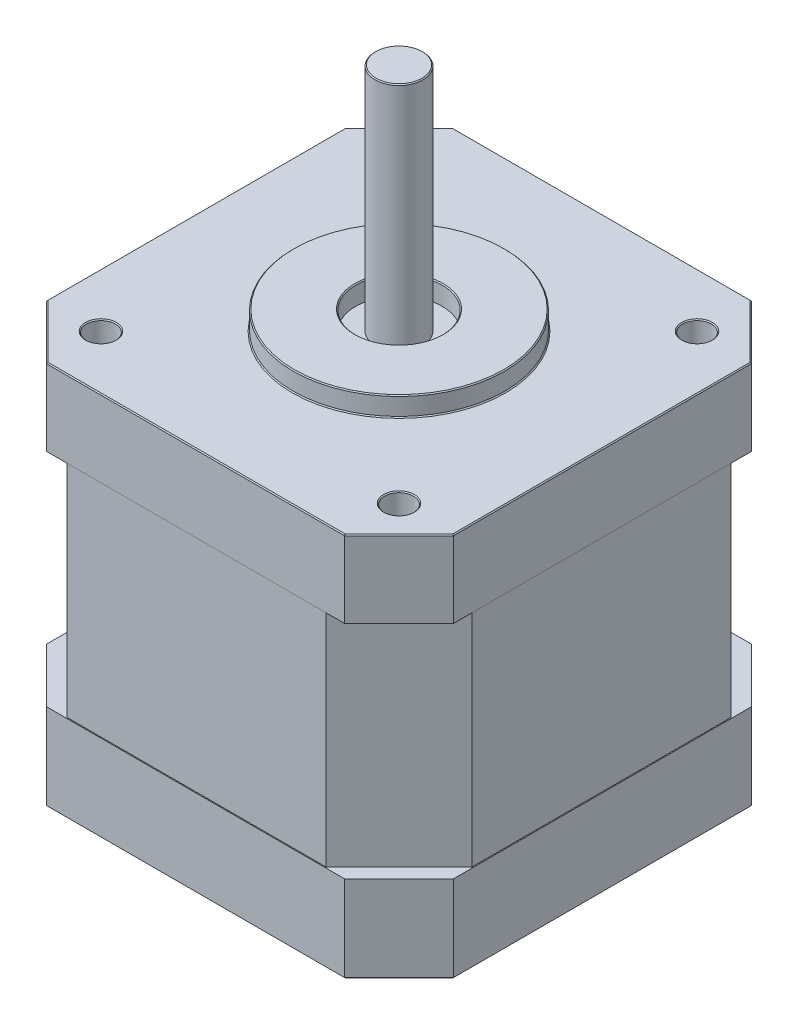
from build123d import *

# Parameters (mm, degrees)
SKETCH1_R           = 1.5
BOSS_EXTRUDE1_DEPTH = 9
SKETCH4_R           = 1.5
BOSS_EXTRUDE4_DEPTH = 23
SKETCH5_R           = 1.5
BOSS_EXTRUDE6_DEPTH = 8
SKETCH2_R           = 11
SKETCH2_R_2         = 4.5
BOSS_EXTRUDE2_DEPTH = 2
SKETCH3_R           = 2.5
BOSS_EXTRUDE3_DEPTH = 24
CHAMFER1_SIZE       = 0.1


with BuildPart() as part:
    # Sketch1 → Boss-Extrude1 (new body)
    with BuildSketch(Plane(origin=(0, 0, 0), x_dir=(1, 0, 0), z_dir=(0, 1, 0))):
        Polygon((-15.5, -21.15), (15.5, -21.15), (21.15, -15.5), (21.15, 15.5), (15.5, 21.15), (-15.5, 21.15), (-21.15, 15.5), (-21.15, -15.5), align=None)
        with Locations((-15.5, 15.5)):
            Circle(SKETCH1_R, mode=Mode.SUBTRACT)
        with Locations((15.5, -15.5)):
            Circle(SKETCH1_R, mode=Mode.SUBTRACT)
        with Locations((15.5, 15.5)):
            Circle(SKETCH1_R, mode=Mode.SUBTRACT)
        with Locations((-15.5, -15.5)):
            Circle(SKETCH1_R, mode=Mode.SUBTRACT)
    extrude(amount=BOSS_EXTRUDE1_DEPTH)

    # Sketch4 → Boss-Extrude4 (add)
    with BuildSketch(Plane(origin=(0, 9, 0), x_dir=(1, 0, 0), z_dir=(0, 1, 0))):
        Polygon((13.478679656, 21.05), (-13.478679656, 21.05), (-21.05, 13.478679656), (-21.05, -13.478679656), (-13.478679656, -21.05), (13.478679656, -21.05), (21.05, -13.478679656), (21.05, 13.478679656), align=None)
        with Locations((-15.5, 15.5)):
            Circle(SKETCH4_R, mode=Mode.SUBTRACT)
        with Locations((15.5, 15.5)):
            Circle(SKETCH4_R, mode=Mode.SUBTRACT)
        with Locations((15.5, -15.5)):
            Circle(SKETCH4_R, mode=Mode.SUBTRACT)
        with Locations((-15.5, -15.5)):
            Circle(SKETCH4_R, mode=Mode.SUBTRACT)
    extrude(amount=BOSS_EXTRUDE4_DEPTH)

    # Sketch5 → Boss-Extrude6 (add)
    with BuildSketch(Plane(origin=(0, 32, 0), x_dir=(1, 0, 0), z_dir=(0, 1, 0))):
        Polygon((-15.5, 21.15), (-21.15, 15.5), (-21.15, -15.5), (-15.5, -21.15), (15.5, -21.15), (21.15, -15.5), (21.15, 15.5), (15.5, 21.15), align=None)
        with Locations((15.5, 15.5)):
            Circle(SKETCH5_R, mode=Mode.SUBTRACT)
        with Locations((-15.5, 15.5)):
            Circle(SKETCH5_R, mode=Mode.SUBTRACT)
        with Locations((-15.5, -15.5)):
            Circle(SKETCH5_R, mode=Mode.SUBTRACT)
        with Locations((15.5, -15.5)):
            Circle(SKETCH5_R, mode=Mode.SUBTRACT)
    extrude(amount=BOSS_EXTRUDE6_DEPTH)

    # Sketch2 → Boss-Extrude2 (add)
    with BuildSketch(Plane(origin=(0, 40, 0), x_dir=(1, 0, 0), z_dir=(0, 1, 0))):
        Circle(SKETCH2_R)
        Circle(SKETCH2_R_2, mode=Mode.SUBTRACT)
    extrude(amount=BOSS_EXTRUDE2_DEPTH)

    # Sketch3 → Boss-Extrude3 (add)
    with BuildSketch(Plane(origin=(0, 40, 0), x_dir=(1, 0, 0), z_dir=(0, 1, 0))):
        Circle(SKETCH3_R)
    extrude(amount=BOSS_EXTRUDE3_DEPTH)

    # Chamfer1
    chamfer1_edges = [part.edges().sort_by_distance(p)[0] for p in [
        (-21.15, 0, 0),
        (-18.325, 0, -18.325),
        (-11, 42, 0),
        (-11, 40, 0),
        (-4.5, 42, 0),
        (-2.5, 64, 0),
        (-17, 0, -15.5),
        (14, 0, 15.5),
        (14, 0, -15.5),
        (-17, 0, 15.5),
        (0, 40, -21.15),
        (-18.325, 40, -18.325),
        (-21.15, 40, 0),
        (-18.325, 40, 18.325),
        (0, 40, 21.15),
        (18.325, 40, 18.325),
        (21.15, 40, 0),
        (18.325, 40, -18.325),
        (0, 0, -21.15),
        (14, 40, -15.5),
        (18.325, 0, -18.325),
        (-17, 40, -15.5),
        (-17, 40, 15.5),
        (14, 40, 15.5),
        (21.15, 0, 0),
        (18.325, 0, 18.325),
        (0, 0, 21.15),
        (-18.325, 0, 18.325),
    ]]
    chamfer(chamfer1_edges, length=CHAMFER1_SIZE)


solid = part.part
